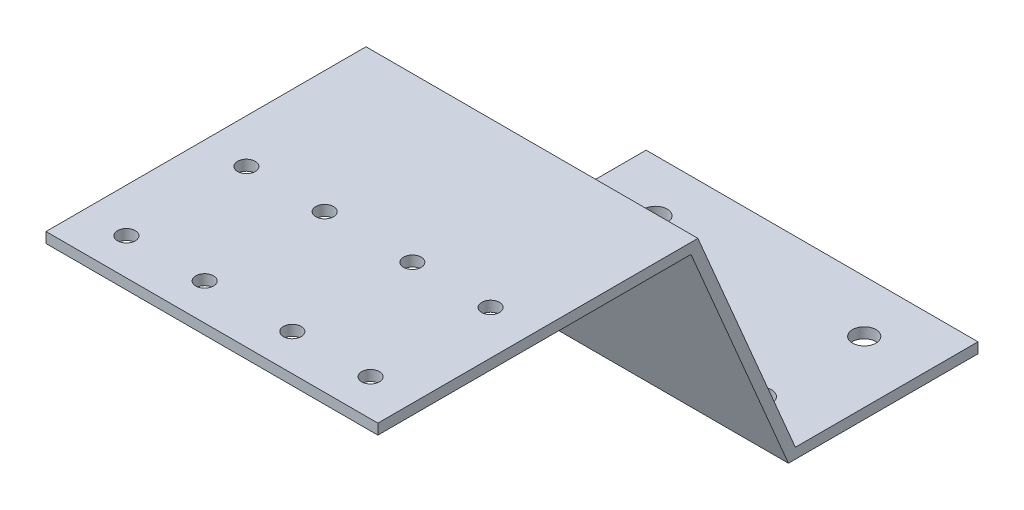
from build123d import *

# Parameters (mm, degrees)
SHEET_EXTRUDE_DEPTH      = 31.8
M3_CLEARANCE_HOLE1_D     = 3.4
M3_CLEARANCE_HOLE1_DEPTH = 8.5
M3_CLEARANCE_HOLE1_TIP   = 1.021463052
M4_CLEARANCE_HOLE1_D     = 4.5
M4_CLEARANCE_HOLE1_DEPTH = 8.5
M4_CLEARANCE_HOLE1_TIP   = 1.351936393


with BuildPart() as part:
    # Sketch2 → Sheet Extrude (new body, symmetric)
    with BuildSketch(Plane(origin=(0, 0, 0), x_dir=(0, 0, -1), z_dir=(1, 0, 0))):
        Polygon((0, 0), (0, 2), (-35, 2), (-53.676209992, 46), (-115, 46), (-115, 44), (-55, 44), (-36.323790008, 0), align=None)
    extrude(amount=SHEET_EXTRUDE_DEPTH, both=True)

    # M3 Clearance Hole1
    with Locations(Plane(origin=(0, 46, 0), x_dir=(1, 0, 0), z_dir=(0, 1, 0))):
        with Locations((-23.4, -108), (-23.4, -85), (-8.4, -85), (-8.4, -108), (23.4, -108), (8.4, -108), (8.4, -85), (23.4, -85)):
            Hole(M3_CLEARANCE_HOLE1_D / 2, depth=M3_CLEARANCE_HOLE1_DEPTH)
            with Locations((0, 0, -(M3_CLEARANCE_HOLE1_DEPTH + M3_CLEARANCE_HOLE1_TIP / 2))):  # 118° drill point
                Cone(0, M3_CLEARANCE_HOLE1_D / 2, M3_CLEARANCE_HOLE1_TIP, mode=Mode.SUBTRACT)

    # M4 Clearance Hole1
    with Locations(Plane(origin=(0, 2, 0), x_dir=(1, 0, 0), z_dir=(0, 1, 0))):
        with Locations((-20, -30), (20, -30), (20, -10), (-20, -10)):
            Hole(M4_CLEARANCE_HOLE1_D / 2, depth=M4_CLEARANCE_HOLE1_DEPTH)
            with Locations((0, 0, -(M4_CLEARANCE_HOLE1_DEPTH + M4_CLEARANCE_HOLE1_TIP / 2))):  # 118° drill point
                Cone(0, M4_CLEARANCE_HOLE1_D / 2, M4_CLEARANCE_HOLE1_TIP, mode=Mode.SUBTRACT)


solid = part.part
